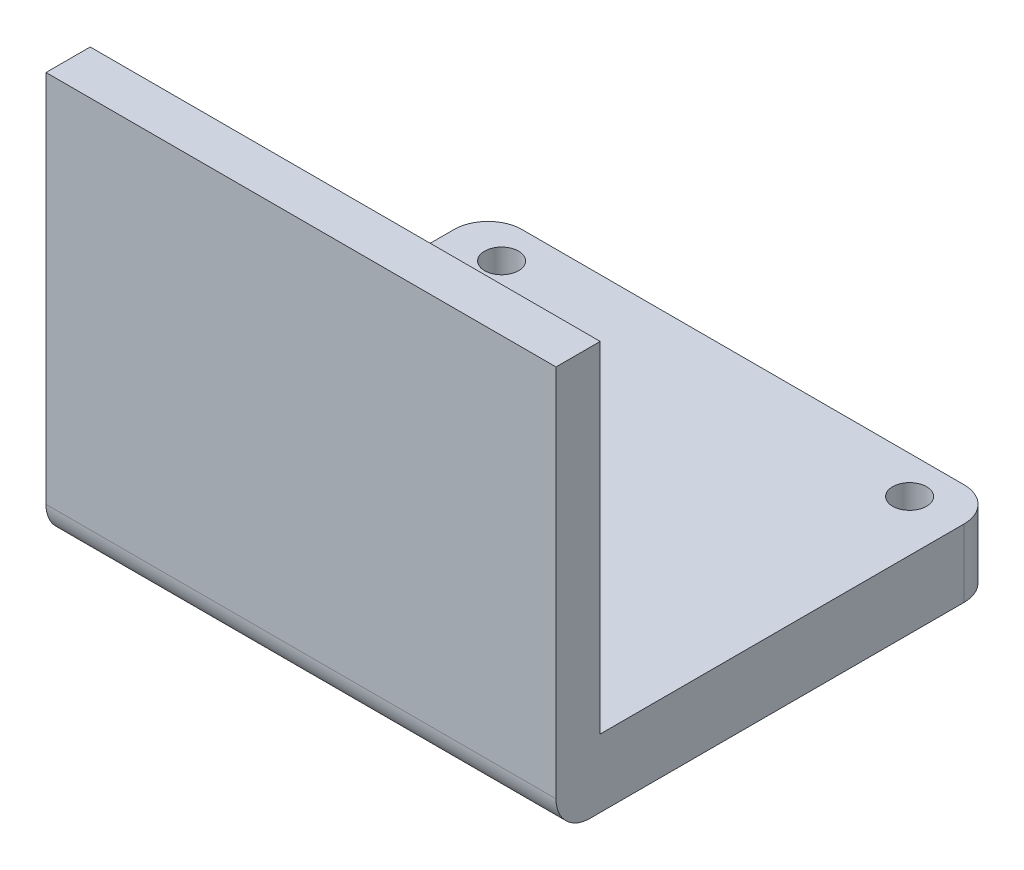
from build123d import *

# Parameters (mm, degrees)
SKETCH1_W           = 75
SKETCH1_H           = 55
SKETCH1_R           = 2.5
BOSS_EXTRUDE1_DEPTH = 10
SKETCH7_W           = 75
SKETCH7_H           = 10
BOSS_EXTRUDE2_DEPTH = 60
SKETCH9_W           = 75
SKETCH9_H           = 3.5
CUT_EXTRUDE5_DEPTH  = 50
FILLET3_R           = 5
FILLET4_R           = 5


with BuildPart() as part:
    # Sketch1 → Boss-Extrude1 (new body)
    with BuildSketch(Plane(origin=(0, 0, 0), x_dir=(1, 0, 0), z_dir=(0, 1, 0))):
        Rectangle(SKETCH1_W, SKETCH1_H)
        with Locations((-30, 22)):
            Circle(SKETCH1_R, mode=Mode.SUBTRACT)
        with Locations((30, 22)):
            Circle(SKETCH1_R, mode=Mode.SUBTRACT)
        with Locations((0, -18)):
            Circle(SKETCH1_R, mode=Mode.SUBTRACT)
    extrude(amount=BOSS_EXTRUDE1_DEPTH)

    # Sketch7 → Boss-Extrude2 (add)
    with BuildSketch(Plane(origin=(0, 0, 0), x_dir=(1, 0, 0), z_dir=(0, 1, 0))):
        with Locations((0, -32.5)):
            Rectangle(SKETCH7_W, SKETCH7_H)
    extrude(amount=BOSS_EXTRUDE2_DEPTH)

    # Sketch9 → Cut-Extrude5 (cut)
    with BuildSketch(Plane(origin=(0, 60, 0), x_dir=(1, 0, 0), z_dir=(0, 1, 0))):
        with Locations((0, -29.25)):
            Rectangle(SKETCH9_W, SKETCH9_H)
    extrude(amount=-CUT_EXTRUDE5_DEPTH, mode=Mode.SUBTRACT)

    # Fillet3
    fillet3_edges = [part.edges().sort_by_distance(p)[0] for p in [
        (0, 0, 37.5),
    ]]
    fillet(fillet3_edges, radius=FILLET3_R)

    # Fillet4
    fillet4_edges = [part.edges().sort_by_distance(p)[0] for p in [
        (-37.5, 5, -27.5),
        (37.5, 5, -27.5),
    ]]
    fillet(fillet4_edges, radius=FILLET4_R)


solid = part.part
